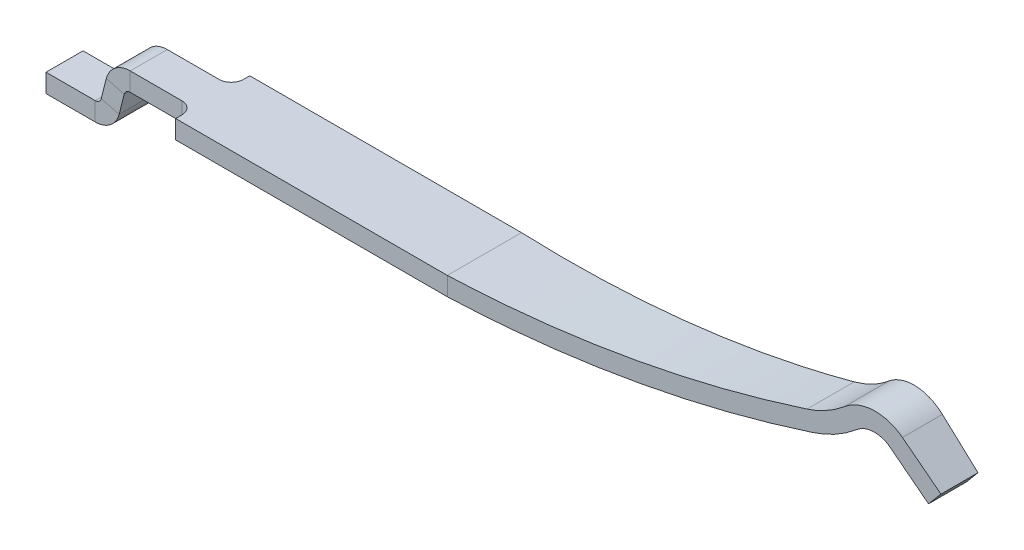
from build123d import *

# Parameters (mm, degrees)
SKETCH1_W           = 0.6
SKETCH1_H           = 0.15
BOSS_EXTRUDE1_DEPTH = 1.7
SKETCH3_W           = 0.3
SKETCH3_H           = 0.15
FILLET1_R           = 0.1
SKETCH6_W           = 0.6
SKETCH6_H           = 0.15
SKETCH8_OUTSIDE_W   = 10.719
SKETCH8_OUTSIDE_H   = 4.072
CUT_EXTRUDE2_DEPTH  = 2.15


with BuildPart() as part:
    # Sketch1 → Boss-Extrude1 (new body)
    with BuildSketch(Plane(origin=(0, 0, 0), x_dir=(0, 0, -1), z_dir=(1, 0, 0))):
        with Locations((0, 0.425)):
            Rectangle(SKETCH1_W, SKETCH1_H)
    extrude(amount=BOSS_EXTRUDE1_DEPTH)

    # Sweep1: sweep along a path in Sketch4
    with BuildLine(Plane.XY) as sweep1_path:
        Line((-1.2, 0), (-0.801686668, 0))
        ThreePointArc((-0.801686668, 0), (-0.679081123, 0.041987722), (-0.607954852, 0.150321198))
        Line((-0.607954852, 0.150321198), (-0.566387806, 0.3124197))
        ThreePointArc((-0.566387806, 0.3124197), (-0.548606238, 0.33950307), (-0.517954852, 0.35))
        Line((-0.517954852, 0.35), (0, 0.35))
    # Sketch3 → Sweep1 (sweep)
    with BuildSketch(Plane(origin=(-1.2, 0, 0), x_dir=(0, 0, -1), z_dir=(1, 0, 0))):
        with Locations((0, 0.075)):
            Rectangle(SKETCH3_W, SKETCH3_H)
    sweep(path=sweep1_path.line)

    # Fillet1
    fillet1_edges = [part.edges().sort_by_distance(p)[0] for p in [
        (0, 0.425, -0.15),
        (0, 0.425, 0.15),
    ]]
    fillet(fillet1_edges, radius=FILLET1_R)

    # Sweep2: sweep along a path in Sketch5
    with BuildLine(Plane.XY) as sweep2_path:
        Line((1.7, 0.35), (2.2, 0.35))
        ThreePointArc((2.2, 0.35), (3.63833241, 0.454572769), (5.046413219, 0.76609166))
        ThreePointArc((5.046413219, 0.76609166), (5.228907253, 0.84171313), (5.392178582, 0.952911835))
        ThreePointArc((5.392178582, 0.952911835), (5.521089291, 1), (5.65, 0.952911835))
        Line((5.65, 0.952911835), (5.95, 0.7))
    # Sketch6 → Sweep2 (sweep)
    with BuildSketch(Plane(origin=(1.7, 0, 0), x_dir=(0, 0, -1), z_dir=(1, 0, 0))):
        with Locations((0, 0.425)):
            Rectangle(SKETCH6_W, SKETCH6_H)
    sweep(path=sweep2_path.line)

    # Sketch8 outside → Cut-Extrude2 (cut, through all)
    with BuildSketch(Plane(origin=(0, 0, 0), x_dir=(1, 0, 0), z_dir=(0, 1, 0))):
        with Locations((2.4235, 0)):
            Rectangle(SKETCH8_OUTSIDE_W, SKETCH8_OUTSIDE_H)
        Polygon((-1.2, 0.432581758), (6.046683032, 0.15), (6.046683032, -0.15), (-1.2, -0.432581758), align=None, mode=Mode.SUBTRACT)
    extrude(amount=CUT_EXTRUDE2_DEPTH, mode=Mode.SUBTRACT)


solid = part.part
